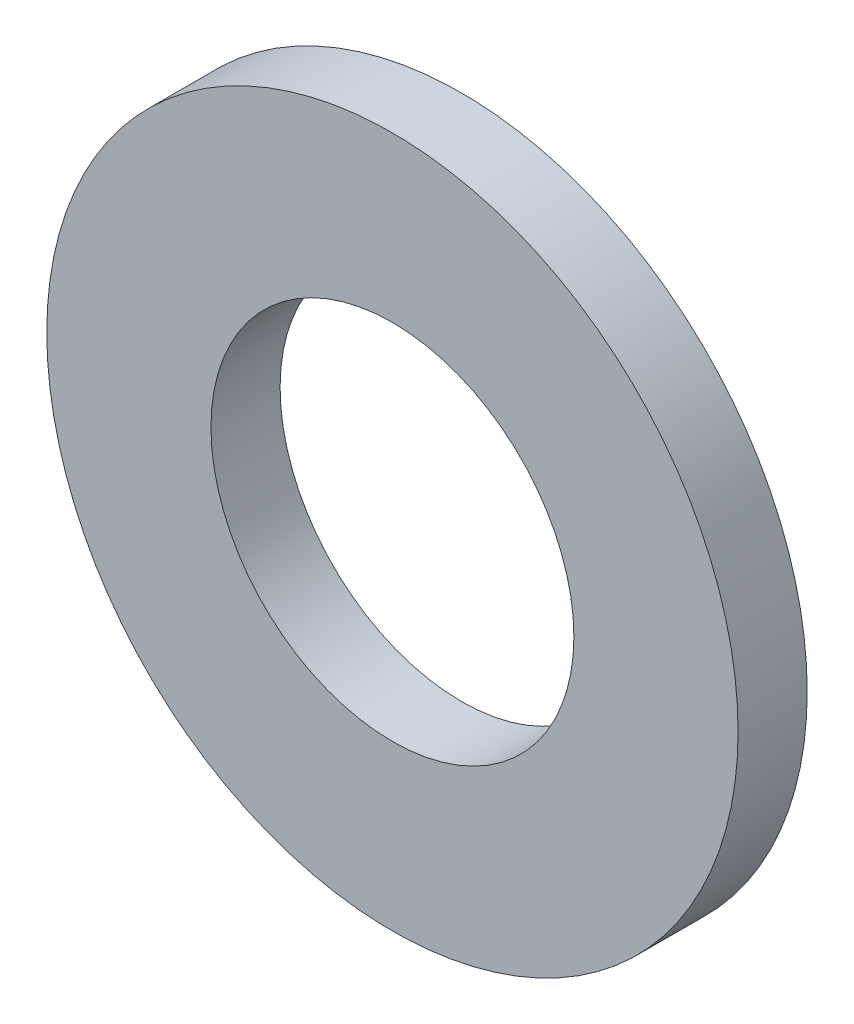
from build123d import *

# Parameters (mm, degrees)
SKETCH3_R                = 10
SKETCH3_R_2              = 5.25
BOSS_EXTRUDE1_DEPTH      = 1
BOSS_EXTRUDE1_DEPTH_BACK = 1


with BuildPart() as part:
    # Sketch3 → Boss-Extrude1 (new body, two sides)
    with BuildSketch(Plane.XY) as boss_extrude1_sk:
        Circle(SKETCH3_R)
        Circle(SKETCH3_R_2, mode=Mode.SUBTRACT)
    extrude(amount=BOSS_EXTRUDE1_DEPTH)
    extrude(boss_extrude1_sk.sketch, amount=-BOSS_EXTRUDE1_DEPTH_BACK)


solid = part.part
